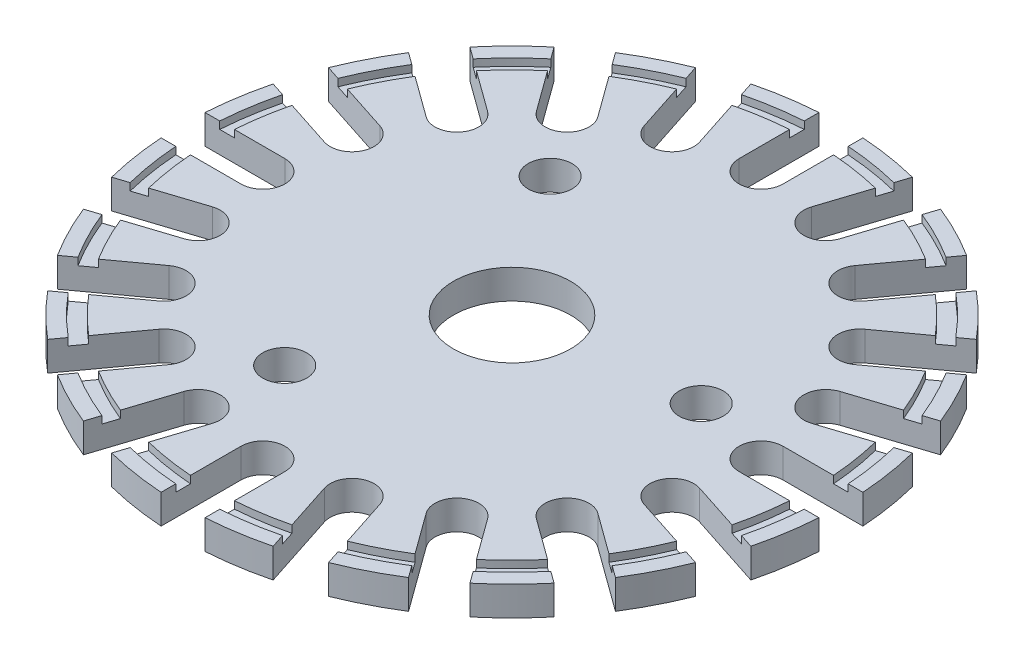
from build123d import *

# Parameters (mm, degrees)
SKETCH1_R           = 22.5
BOSS_EXTRUDE1_DEPTH = 2
CUT_EXTRUDE1_DEPTH  = 2
CIRPATTERN1_COUNT   = 20
SKETCH3_R           = 21.5
SKETCH3_R_2         = 20.5
CUT_EXTRUDE2_DEPTH  = 0.5
SKETCH4_R           = 4
CUT_EXTRUDE3_DEPTH  = 3
SKETCH5_R           = 1.5
CUT_EXTRUDE4_DEPTH  = 10


with BuildPart() as part:
    # Sketch1 → Boss-Extrude1 (new body)
    with BuildSketch(Plane(origin=(0, 0, 0), x_dir=(1, 0, 0), z_dir=(0, 1, 0))):
        Circle(SKETCH1_R)
    extrude(amount=BOSS_EXTRUDE1_DEPTH)

    # Sketch2 → Cut-Extrude1 (cut)
    with BuildSketch(Plane(origin=(0, 2, 0), x_dir=(1, 0, 0), z_dir=(0, 1, 0))):
        with BuildLine():
            Line((1.5, 22.795822005), (1.5, 17))
            ThreePointArc((1.5, 17), (0, 15.5), (-1.5, 17))
            Line((-1.5, 17), (-1.5, 22.795822005))
            ThreePointArc((-1.5, 22.795822005), (0, 24.295822005), (1.5, 22.795822005))
        make_face()
    cut_extrude1 = extrude(amount=-CUT_EXTRUDE1_DEPTH, mode=Mode.SUBTRACT)

    # CirPattern1: Cut-Extrude1 ×20 about axis
    cirpattern1_axis = Axis((0, 0, 0), (0, 1, 0))
    for i in range(1, CIRPATTERN1_COUNT):
        add(cut_extrude1.rotate(cirpattern1_axis, i * 360 / CIRPATTERN1_COUNT), mode=Mode.SUBTRACT)

    # Sketch3 → Cut-Extrude2 (cut)
    with BuildSketch(Plane(origin=(0, 2, 0), x_dir=(1, 0, 0), z_dir=(0, 1, 0))):
        Circle(SKETCH3_R)
        Circle(SKETCH3_R_2, mode=Mode.SUBTRACT)
    extrude(amount=-CUT_EXTRUDE2_DEPTH, mode=Mode.SUBTRACT)

    # Sketch4 → Cut-Extrude3 (cut, through all)
    with BuildSketch(Plane(origin=(0, 2, 0), x_dir=(1, 0, 0), z_dir=(0, 1, 0))):
        Circle(SKETCH4_R)
    extrude(amount=-CUT_EXTRUDE3_DEPTH, mode=Mode.SUBTRACT)

    # Sketch5 → Cut-Extrude4 (cut)
    with BuildSketch(Plane.XZ):
        with Locations((-4.779155556, 10.734159127)):
            Circle(SKETCH5_R)
        with Locations((11.685632271, -1.228209443)):
            Circle(SKETCH5_R)
        with Locations((-6.906476714, -9.505949684)):
            Circle(SKETCH5_R)
    extrude(amount=-CUT_EXTRUDE4_DEPTH, mode=Mode.SUBTRACT)


solid = part.part
